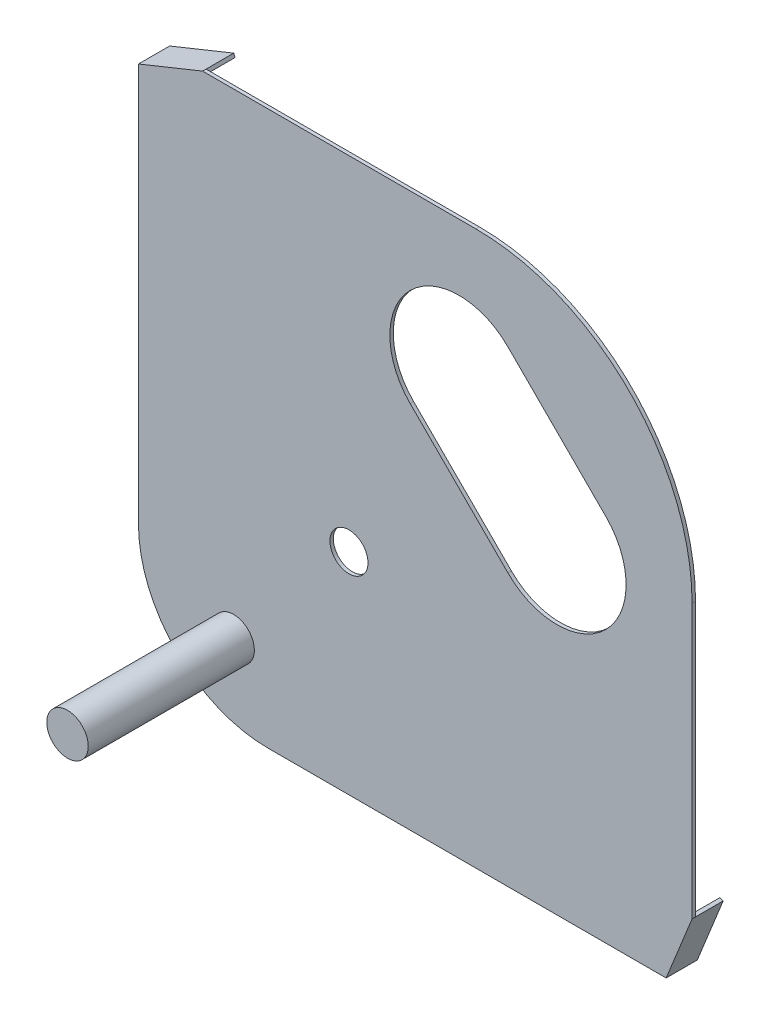
from build123d import *

# Parameters (mm, degrees)
BOSS_EXTRUDE1_DEPTH = 0.254
SKETCH2_R           = 2.032
CUT_EXTRUDE1_DEPTH  = 0.254
SKETCH3_R           = 1.397
CUT_EXTRUDE2_DEPTH  = 0.254
CUT_EXTRUDE3_DEPTH  = 0.254
SKETCH5_R           = 1.524
BOSS_EXTRUDE2_DEPTH = 12.192
BOSS_EXTRUDE3_DEPTH = 2.286
SKETCH8_R           = 2.05178126
BOSS_EXTRUDE4_DEPTH = 0.254
SKETCH9_W           = 2.585879879
SKETCH9_H           = 0.671823721
CUT_EXTRUDE4_DEPTH  = 31.895819587


with BuildPart() as part:
    # Sketch1 → Boss-Extrude1 (new body)
    with BuildSketch(Plane.XY):
        with BuildLine():
            Line((0, -9.525), (29.211998505, -9.525))
            Line((29.211998505, -9.525), (31.115, -4.814906019))
            Line((31.115, -4.814906019), (31.115, 15.24))
            ThreePointArc((31.115, 15.24), (26.465320151, 26.465320151), (15.24, 31.115))
            Line((15.24, 31.115), (-4.814906019, 31.115))
            Line((-4.814906019, 31.115), (-9.525, 29.211998505))
            Line((-9.525, 29.211998505), (-9.525, 0))
            ThreePointArc((-9.525, 0), (-6.735192091, -6.735192091), (0, -9.525))
        make_face()
    extrude(amount=-BOSS_EXTRUDE1_DEPTH)

    # Sketch2 → Cut-Extrude1 (cut)
    with BuildSketch(Plane.XY):
        Circle(SKETCH2_R)
    extrude(amount=-CUT_EXTRUDE1_DEPTH, mode=Mode.SUBTRACT)

    # Sketch3 → Cut-Extrude2 (cut)
    with BuildSketch(Plane.XY):
        with Locations((5.92696904, 5.92696904)):
            Circle(SKETCH3_R)
    extrude(amount=-CUT_EXTRUDE2_DEPTH, mode=Mode.SUBTRACT)

    # Sketch4 → Cut-Extrude3 (cut)
    with BuildSketch(Plane.XY):
        with BuildLine():
            Line((17.601301997, 24.785506894), (24.785506894, 17.601301997))
            ThreePointArc((24.785506894, 17.601301997), (24.785506894, 10.4170971), (17.601301997, 10.4170971))
            Line((17.601301997, 10.4170971), (10.4170971, 17.601301997))
            ThreePointArc((10.4170971, 17.601301997), (10.4170971, 24.785506894), (17.601301997, 24.785506894))
        make_face()
    extrude(amount=-CUT_EXTRUDE3_DEPTH, mode=Mode.SUBTRACT)

    # Sketch5 → Boss-Extrude2 (add)
    with BuildSketch(Plane.XY):
        with Locations((-2.54, -3.81)):
            Circle(SKETCH5_R)
    extrude(amount=BOSS_EXTRUDE2_DEPTH)

    # Sketch7 → Boss-Extrude3 (add)
    with BuildSketch(Plane.XY):
        Polygon((29.211998505, -9.525), (28.976493806, -9.429849925), (30.879495301, -4.719755944), (31.115, -4.814906019), align=None)
        with BuildLine():
            Line((27.708062292, 24.654775211), (27.887667414, 24.834380333))
            ThreePointArc((27.887667414, 24.834380333), (26.465320151, 26.465320151), (24.834380333, 27.887667414))
            Line((24.834380333, 27.887667414), (24.654775211, 27.708062292))
            Line((24.654775211, 27.708062292), (27.708062292, 24.654775211))
        make_face()
        Polygon((-9.525, 29.211998505), (-9.429849925, 28.976493806), (-4.719755944, 30.879495301), (-4.814906019, 31.115), align=None)
    extrude(amount=-BOSS_EXTRUDE3_DEPTH)

    # Sketch8 → Boss-Extrude4 (add)
    with BuildSketch(Plane.XY):
        Circle(SKETCH8_R)
    extrude(amount=-BOSS_EXTRUDE4_DEPTH)

    # Sketch9 → Cut-Extrude4 (cut, through all)
    with BuildSketch(Plane(origin=(-1.526643541, 1.526643541, 0), x_dir=(0, 0, 1), z_dir=(-0.707106781, 0.707106781, 0))):
        with Locations((-1.54693994, 37.362029341)):
            Rectangle(SKETCH9_W, SKETCH9_H)
    extrude(amount=-CUT_EXTRUDE4_DEPTH, mode=Mode.SUBTRACT)


solid = part.part
